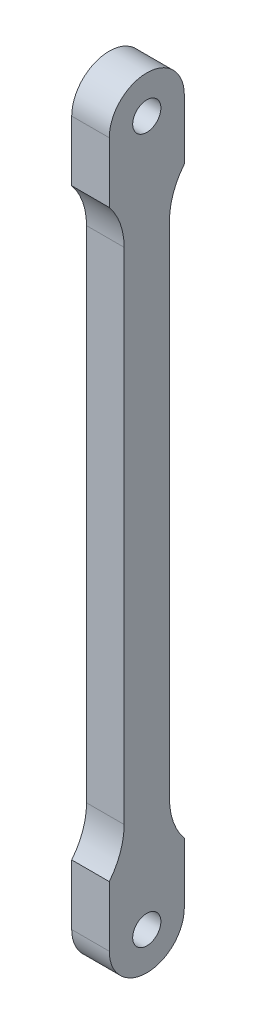
from build123d import *

# Parameters (mm, degrees)
SKETCH1_R               = 10
SKETCH1_R_2             = 0.8
SKETCH1_R_3             = 3.301767793
BOSS_EXTRUDE1_DEPTH     = 1.5
SKETCH2_R               = 10
BOSS_EXTRUDE2_DEPTH     = 9
SKETCH3_R               = 1.5
CUT_EXTRUDE1_DEPTH      = 1
CUT_EXTRUDE1_DEPTH_BACK = 10
FILLET1_R               = 5
SKETCH4_R               = 1.5
BOSS_EXTRUDE3_DEPTH     = 4
SKETCH5_W               = 43.786924739
SKETCH5_H               = 105.486682325
CUT_EXTRUDE2_DEPTH      = 5
CUT_EXTRUDE2_DEPTH_BACK = 10.0000001
CUT_EXTRUDE3_DEPTH      = 1
CUT_EXTRUDE3_DEPTH_BACK = 5


with BuildPart() as part:
    # Sketch1 → Boss-Extrude1 (new body)
    with BuildSketch(Plane(origin=(0, 0, 0), x_dir=(0, 0, -1), z_dir=(1, 0, 0))):
        with Locations((2.983378847, 10.826778074)):
            Circle(SKETCH1_R)
        with Locations((2.983378847, 18.576778074)):
            Circle(SKETCH1_R_2, mode=Mode.SUBTRACT)
        with Locations((2.983378847, 3.076778074)):
            Circle(SKETCH1_R_2, mode=Mode.SUBTRACT)
        with Locations((-3.266621153, 10.826778074)):
            Circle(SKETCH1_R_2, mode=Mode.SUBTRACT)
        with Locations((9.233378847, 10.826778074)):
            Circle(SKETCH1_R_2, mode=Mode.SUBTRACT)
        with Locations((2.983378847, 10.826778074)):
            Circle(SKETCH1_R_3, mode=Mode.SUBTRACT)
    extrude(amount=BOSS_EXTRUDE1_DEPTH)

    # Sketch2 → Boss-Extrude2 (add)
    with BuildSketch(Plane.ZY):
        with BuildLine():
            Line((-15.531923741, 95.891603494), (9.565166047, 95.891603494))
            Line((9.565166047, 95.891603494), (9.565166047, 10.826778074))
            ThreePointArc((9.565166047, 10.826778074), (-2.983378847, -1.721766821), (-15.531923741, 10.826778074))
            Line((-15.531923741, 10.826778074), (-15.531923741, 95.891603494))
        make_face()
        with Locations((-2.983378847, 10.826778074)):
            Circle(SKETCH2_R, mode=Mode.SUBTRACT)
    extrude(amount=-BOSS_EXTRUDE2_DEPTH)

    # Sketch3 → Cut-Extrude1 (cut, two sides)
    with BuildSketch(Plane(origin=(9, 0, 0), x_dir=(0, 0, -1), z_dir=(1, 0, 0))) as cut_extrude1_sk:
        with Locations((2.983378847, 90.473665847)):
            Circle(SKETCH3_R)
        with BuildLine():
            Line((-3.051129507, 36.150412664), (-3.051129507, 97.572569437))
            Line((-3.051129507, 97.572569437), (-16.389018159, 97.572569437))
            Line((-16.389018159, 97.572569437), (-16.389018159, 8.14109285))
            Line((-16.389018159, 8.14109285), (-9.565166047, 10.826778074))
            add(Edge.make_bspline(
                [(-9.565166047, 10.826778074), (-9.644230884, 15.122204253), (-6.916245701, 23.507010268), (-3.42826878, 31.561714956), (-3.051129507, 36.150412664)],
                knots=[0, 0, 0, 0, 0.482384809, 1, 1, 1, 1], degree=3))
        make_face()
        with BuildLine():
            Line((22.355775853, 8.14109285), (15.531923741, 10.826778074))
            add(Edge.make_bspline(
                [(15.531923741, 10.826778074), (15.610988578, 15.122204253), (12.883003395, 23.507010268), (9.395026474, 31.561714956), (9.017887201, 36.150412664)],
                knots=[0, 0, 0, 0, 0.482384809, 1, 1, 1, 1], degree=3))
            Line((9.017887201, 36.150412664), (9.017887201, 97.572569437))
            Line((9.017887201, 97.572569437), (22.355775853, 97.572569437))
            Line((22.355775853, 97.572569437), (22.355775853, 8.14109285))
        make_face()
    extrude(amount=CUT_EXTRUDE1_DEPTH, mode=Mode.SUBTRACT)
    extrude(cut_extrude1_sk.sketch, amount=-CUT_EXTRUDE1_DEPTH_BACK, mode=Mode.SUBTRACT)

    # Fillet1
    fillet1_edges = [part.edges().sort_by_distance(p)[0] for p in [
        (4.5, 95.891603494, 3.051129507),
        (4.5, 95.891603494, -9.017887201),
    ]]
    fillet(fillet1_edges, radius=FILLET1_R)

    # Sketch5 → Cut-Extrude2 (cut, two sides)
    with BuildSketch(Plane(origin=(9, 0, 0), x_dir=(0, 0, -1), z_dir=(1, 0, 0))) as cut_extrude2_sk:
        with Locations((-1.981744939, 44.563852974)):
            Rectangle(SKETCH5_W, SKETCH5_H)
    extrude(amount=CUT_EXTRUDE2_DEPTH, mode=Mode.SUBTRACT)
    extrude(cut_extrude2_sk.sketch, amount=-CUT_EXTRUDE2_DEPTH_BACK, mode=Mode.SUBTRACT)


with BuildPart() as body_2:
    # Sketch4 → Boss-Extrude3 (new body)
    with BuildSketch(Plane(origin=(9, 0, 0), x_dir=(0, 0, -1), z_dir=(1, 0, 0))):
        with BuildLine():
            Line((38.773588851, 85.849332764), (38.773588851, 10.849332764))
            ThreePointArc((38.773588851, 10.849332764), (34.779514456, 6.855258369), (30.785440062, 10.849332764))
            Line((30.785440062, 10.849332764), (30.785440062, 85.849332764))
            ThreePointArc((30.785440062, 85.849332764), (34.779514456, 89.843407159), (38.773588851, 85.849332764))
        make_face()
        with Locations((34.779514456, 85.849332764)):
            Circle(SKETCH4_R, mode=Mode.SUBTRACT)
        with Locations((34.779514456, 10.849332764)):
            Circle(SKETCH4_R, mode=Mode.SUBTRACT)
    extrude(amount=BOSS_EXTRUDE3_DEPTH)

    # Sketch6 → Cut-Extrude3 (cut, two sides)
    with BuildSketch(Plane(origin=(13, 0, 0), x_dir=(0, 0, -1), z_dir=(1, 0, 0))) as cut_extrude3_sk:
        with BuildLine():
            Line((32.368772821, 74.957140703), (32.368772821, 21.741524825))
            ThreePointArc((32.368772821, 21.741524825), (25.269119008, 14.641871012), (18.169465194, 21.741524825))
            Line((18.169465194, 21.741524825), (18.169465194, 74.957140703))
            ThreePointArc((18.169465194, 74.957140703), (25.269119008, 82.056794517), (32.368772821, 74.957140703))
        make_face()
        with BuildLine():
            Line((37.190256091, 74.957140703), (37.190256091, 21.741524825))
            ThreePointArc((37.190256091, 21.741524825), (44.289909905, 14.641871012), (51.389563719, 21.741524825))
            Line((51.389563719, 21.741524825), (51.389563719, 74.957140703))
            ThreePointArc((51.389563719, 74.957140703), (44.289909905, 82.056794517), (37.190256091, 74.957140703))
        make_face()
    extrude(amount=CUT_EXTRUDE3_DEPTH, mode=Mode.SUBTRACT)
    extrude(cut_extrude3_sk.sketch, amount=-CUT_EXTRUDE3_DEPTH_BACK, mode=Mode.SUBTRACT)


solid = body_2.part
